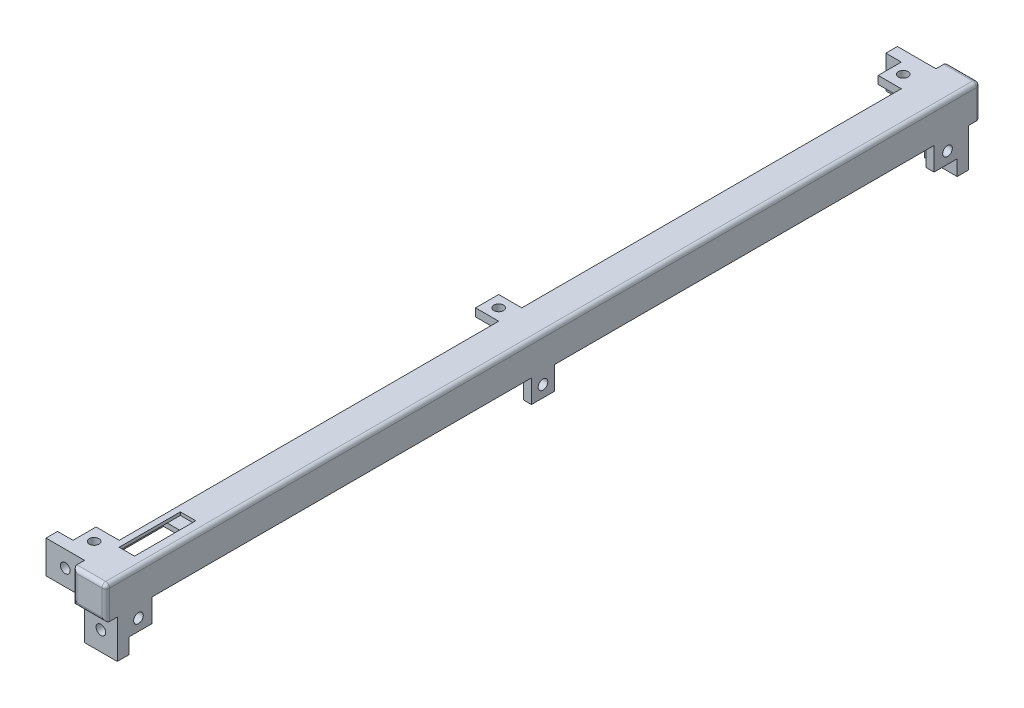
from build123d import *

# Parameters (mm, degrees)
ESBO_O1_W                = 8.5
ESBO_O1_H                = 8.5
RESSALTO_EXTRUS_O1_DEPTH = 227
FILETE1_R                = 1
FILETE2_R                = 1
FILETE3_R                = 1
ESBO_O2_W                = 215
ESBO_O2_H                = 6.45
CORTE_EXTRUS_O2_DEPTH    = 3.6
ESBO_O3_W                = 3
ESBO_O3_H                = 8.5
RESSALTO_EXTRUS_O3_DEPTH = 10
ESBO_O4_W                = 8.5
ESBO_O4_H                = 3
RESSALTO_EXTRUS_O4_DEPTH = 10
ESBO_O5_W                = 6
ESBO_O5_H                = 2.05
RESSALTO_EXTRUS_O5_DEPTH = 6
ESBO_O6_W                = 2.05
ESBO_O6_H                = 6
RESSALTO_EXTRUS_O6_DEPTH = 6
ESBO_O6_2_W              = 2.05
ESBO_O6_2_H              = 6
RESSALTO_EXTRUS_O7_DEPTH = 6
ESBO_O7_R                = 1.25
CORTE_EXTRUS_O3_DEPTH    = 250
ESBO_O8_R                = 1.25
CORTE_EXTRUS_O4_DEPTH    = 5
ESBO_O9_R                = 1.25
CORTE_EXTRUS_O5_DEPTH    = 5
ESBO_O11_W               = 2.9
ESBO_O11_H               = 13
CORTE_EXTRUS_O6_DEPTH    = 7.7
ESBO_O15_W               = 13
ESBO_O15_H               = 7.7
CORTE_EXTRUS_O10_DEPTH   = 5.9
ESBO_O16_W               = 4
ESBO_O16_H               = 12.5
CORTE_EXTRUS_O12_DEPTH   = 5.9
ESBO_O17_W               = 4
ESBO_O17_H               = 3.401907962
CORTE_EXTRUS_O14_DEPTH   = 0.8


with BuildPart() as part:
    # Esboço1 → Ressalto-extrusão1 (new body)
    with BuildSketch(Plane.XY):
        Rectangle(ESBO_O1_W, ESBO_O1_H)
    extrude(amount=RESSALTO_EXTRUS_O1_DEPTH)

    # Filete1
    filete1_edges = [part.edges().sort_by_distance(p)[0] for p in [
        (4.25, 4.25, 113.5),
    ]]
    fillet(filete1_edges, radius=FILETE1_R)

    # Filete2
    filete2_edges = [part.edges().sort_by_distance(p)[0] for p in [
        (0, -4.25, 227),
        (-4.25, 0, 227),
        (-0.5, 4.25, 227),
        (3.957106781, 3.957106781, 227),
        (4.25, -0.5, 227),
    ]]
    fillet(filete2_edges, radius=FILETE2_R)

    # Filete3
    filete3_edges = [part.edges().sort_by_distance(p)[0] for p in [
        (-4.25, 0, 0),
        (0, -4.25, 0),
        (4.25, -0.5, 0),
        (3.957106781, 3.957106781, 0),
        (-0.5, 4.25, 0),
    ]]
    fillet(filete3_edges, radius=FILETE3_R)

    # Esboço2 → Corte-extrusão2 (cut)
    with BuildSketch(Plane.ZY.offset(4.25)):
        with Locations((113.5, -1.025)):
            Rectangle(ESBO_O2_W, ESBO_O2_H)
    extrude(amount=-CORTE_EXTRUS_O2_DEPTH, mode=Mode.SUBTRACT)

    # Esboço3 → Ressalto-extrusão3 (add)
    with BuildSketch(Plane.ZY.offset(4.25)):
        with Locations((4.5, 0)):
            Rectangle(ESBO_O3_W, ESBO_O3_H)
        with Locations((222.5, 0)):
            Rectangle(ESBO_O3_W, ESBO_O3_H)
    extrude(amount=RESSALTO_EXTRUS_O3_DEPTH)

    # Esboço4 → Ressalto-extrusão4 (add)
    with BuildSketch(Plane.XZ.offset(4.25)):
        with Locations((0, 222.5)):
            Rectangle(ESBO_O4_W, ESBO_O4_H)
        with Locations((0, 4.5)):
            Rectangle(ESBO_O4_W, ESBO_O4_H)
    extrude(amount=RESSALTO_EXTRUS_O4_DEPTH)

    # Esboço5 → Ressalto-extrusão5 (add)
    with BuildSketch(Plane.ZY.offset(4.25)):
        with Locations((9, 3.225)):
            Rectangle(ESBO_O5_W, ESBO_O5_H)
        with Locations((218, 3.225)):
            Rectangle(ESBO_O5_W, ESBO_O5_H)
        with Locations((113.5, 3.225)):
            Rectangle(ESBO_O5_W, ESBO_O5_H)
    extrude(amount=RESSALTO_EXTRUS_O5_DEPTH)

    # Esboço6 → Ressalto-extrusão6 (add)
    with BuildSketch(Plane.XZ.offset(4.25)):
        with Locations((3.225, 9)):
            Rectangle(ESBO_O6_W, ESBO_O6_H)
        Polygon((4.25, 113.5), (4.25, 116.5), (2.2, 116.5), (2.2, 110.5), (4.25, 110.5), align=None)
        with Locations((3.225, 218)):
            Rectangle(ESBO_O6_W, ESBO_O6_H)
    extrude(amount=RESSALTO_EXTRUS_O6_DEPTH)

    # Esboço6<2> → Ressalto-extrusão7 (add)
    with BuildSketch(Plane.XZ.offset(4.25)):
        with Locations((3.225, 9)):
            Rectangle(ESBO_O6_2_W, ESBO_O6_2_H)
        Polygon((4.25, 113.5), (4.25, 116.5), (2.2, 116.5), (2.2, 110.5), (4.25, 110.5), align=None)
        with Locations((3.225, 218)):
            Rectangle(ESBO_O6_2_W, ESBO_O6_2_H)
    extrude(amount=RESSALTO_EXTRUS_O7_DEPTH)

    # Esboço7 → Corte-extrusão3 (cut)
    with BuildSketch(Plane.XY.offset(224)):
        with Locations((-9.25, 0)):
            Circle(ESBO_O7_R)
        with Locations((0, -9.25)):
            Circle(ESBO_O7_R)
    extrude(amount=-CORTE_EXTRUS_O3_DEPTH, mode=Mode.SUBTRACT)

    # Esboço8 → Corte-extrusão4 (cut)
    with BuildSketch(Plane(origin=(4.25, 0, 0), x_dir=(0, 0, -1), z_dir=(1, 0, 0))):
        with Locations((-218.5, -7.25)):
            Circle(ESBO_O8_R)
        with Locations((-113.5, -7.25)):
            Circle(ESBO_O8_R)
        with Locations((-8.5, -7.25)):
            Circle(ESBO_O8_R)
    extrude(amount=-CORTE_EXTRUS_O4_DEPTH, mode=Mode.SUBTRACT)

    # Esboço9 → Corte-extrusão5 (cut)
    with BuildSketch(Plane(origin=(0, 4.25, 0), x_dir=(1, 0, 0), z_dir=(0, 1, 0))):
        with Locations((-7.25, -218.5)):
            Circle(ESBO_O9_R)
        with Locations((-7.25, -113.5)):
            Circle(ESBO_O9_R)
        with Locations((-7.25, -8.5)):
            Circle(ESBO_O9_R)
    extrude(amount=-CORTE_EXTRUS_O5_DEPTH, mode=Mode.SUBTRACT)

    # Esboço11 → Corte-extrusão6 (cut)
    with BuildSketch(Plane.XZ.offset(4.25)):
        with Locations((0.8, 210.578920039)):
            Rectangle(ESBO_O11_W, ESBO_O11_H)
    extrude(amount=-CORTE_EXTRUS_O6_DEPTH, mode=Mode.SUBTRACT)

    # Esboço15 → Corte-extrusão10 (cut)
    with BuildSketch(Plane.ZY.offset(-2.25)):
        with Locations((210.578920039, -0.4)):
            Rectangle(ESBO_O15_W, ESBO_O15_H)
    extrude(amount=CORTE_EXTRUS_O10_DEPTH, mode=Mode.SUBTRACT)

    # Esboço16 → Corte-extrusão12 (cut)
    with BuildSketch(Plane.XZ.offset(-3.45)):
        with Locations((-0.7, 210.328920039)):
            Rectangle(ESBO_O16_W, ESBO_O16_H)
    extrude(amount=-CORTE_EXTRUS_O12_DEPTH, mode=Mode.SUBTRACT)

    # Esboço17 → Corte-extrusão14 (cut)
    with BuildSketch(Plane(origin=(0, 4.25, 0), x_dir=(1, 0, 0), z_dir=(0, 1, 0))):
        with Locations((-0.7, -202.377966058)):
            Rectangle(ESBO_O17_W, ESBO_O17_H)
    extrude(amount=-CORTE_EXTRUS_O14_DEPTH, mode=Mode.SUBTRACT)


solid = part.part
